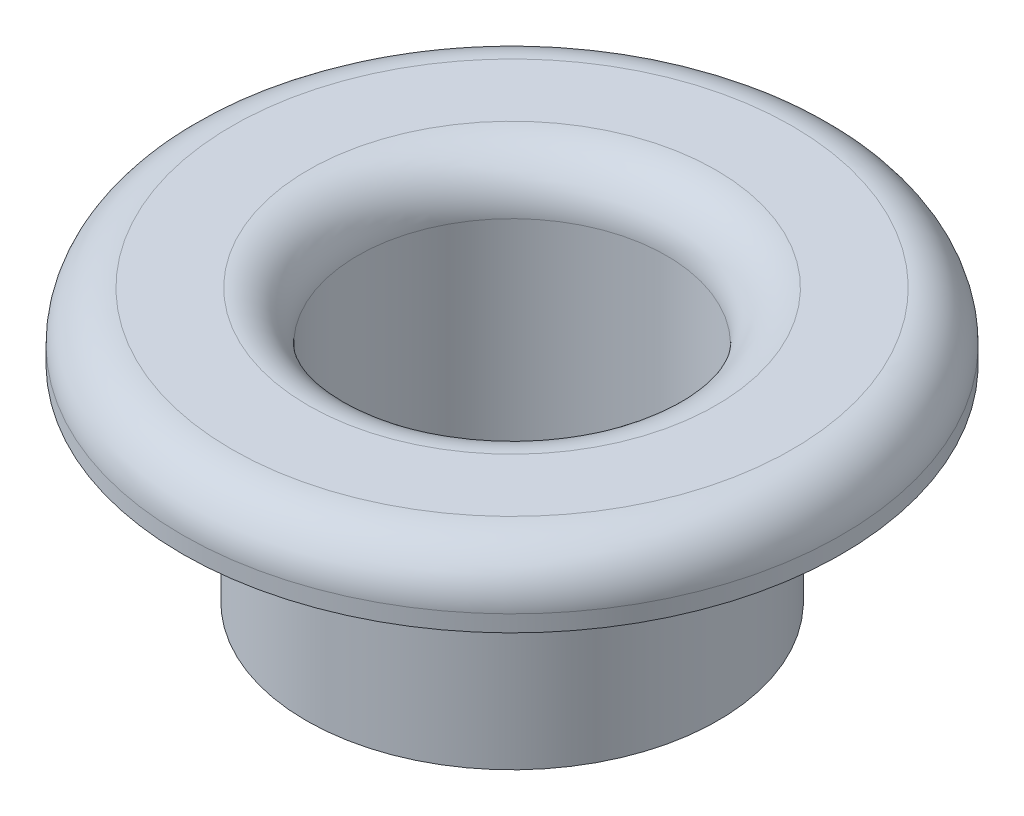
from build123d import *

# Parameters (mm, degrees)
SKETCH1_R           = 3.175
SKETCH1_R_2         = 2.38125
BOSS_EXTRUDE1_DEPTH = 3.175
SKETCH2_R           = 5.08
SKETCH2_R_2         = 2.38125
BOSS_EXTRUDE2_DEPTH = 1.016
FILLET1_R           = 0.762


with BuildPart() as part:
    # Sketch1 → Boss-Extrude1 (new body)
    with BuildSketch(Plane(origin=(0, 0, 0), x_dir=(1, 0, 0), z_dir=(0, 1, 0))):
        Circle(SKETCH1_R)
        Circle(SKETCH1_R_2, mode=Mode.SUBTRACT)
    extrude(amount=BOSS_EXTRUDE1_DEPTH)

    # Sketch2 → Boss-Extrude2 (add)
    with BuildSketch(Plane(origin=(0, 3.175, 0), x_dir=(1, 0, 0), z_dir=(0, 1, 0))):
        Circle(SKETCH2_R)
        Circle(SKETCH2_R_2, mode=Mode.SUBTRACT)
    extrude(amount=BOSS_EXTRUDE2_DEPTH)

    # Fillet1
    fillet1_edges = [part.edges().sort_by_distance(p)[0] for p in [
        (-2.38125, 4.191, 0),
        (-5.08, 4.191, 0),
    ]]
    fillet(fillet1_edges, radius=FILLET1_R)


solid = part.part
